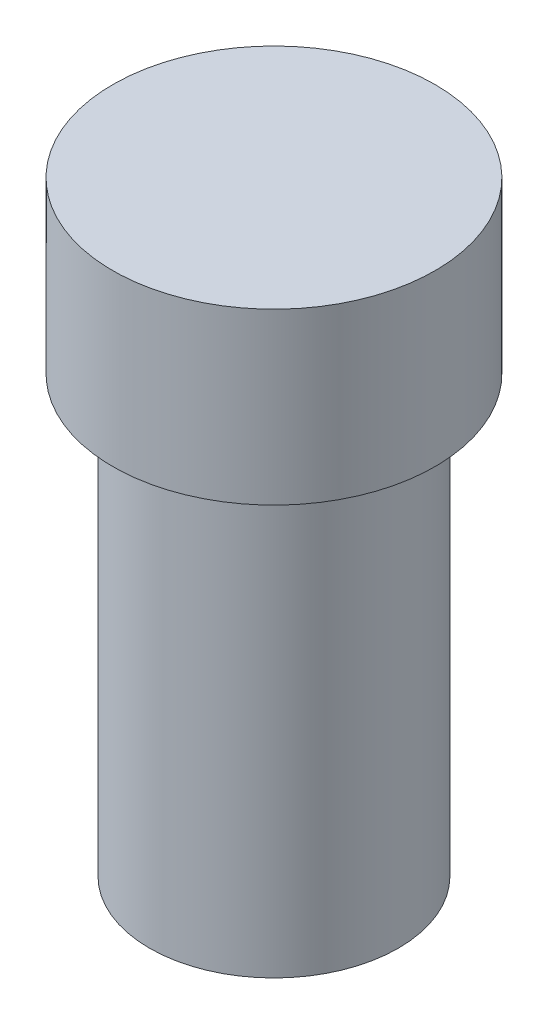
from build123d import *

# Parameters (mm, degrees)
FILLET1_R = 2


with BuildPart() as part:
    # Sketch1 → Revolve1 (revolve)
    with BuildSketch(Plane.XY, mode=Mode.PRIVATE) as revolve1_sk:
        Polygon((0, 0), (22, 0), (22, 77), (28.5, 77), (28.5, 107), (0, 107), align=None)
    revolve(revolve1_sk.sketch.rotate(Axis((0, 0, 0), (0, 1, 0)), 90), axis=Axis((0, 0, 0), (0, 1, 0)))  # turned: the seam where the file's is

    # Fillet1
    fillet1_edges = [part.edges().sort_by_distance(p)[0] for p in [
        (0, 77, 22),
    ]]
    fillet(fillet1_edges, radius=FILLET1_R)


solid = part.part
